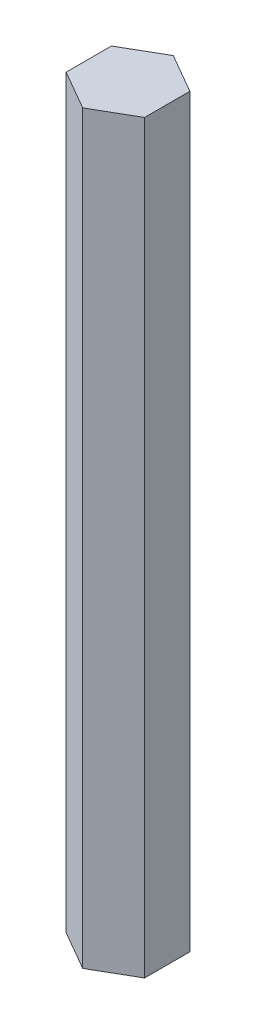
from build123d import *

# Parameters (mm, degrees)
BOSS_EXTRUDE1_DEPTH              = 120.65
F_10_32_TAPPED_HOLE1_D           = 4.0386
F_10_32_TAPPED_HOLE1_DEPTH       = 16.764
F_10_32_TAPPED_HOLE1_CBORE_D     = 4.826
F_10_32_TAPPED_HOLE1_CBORE_DEPTH = 12.7
F_10_32_TAPPED_HOLE1_TIP         = 1.213317848


with BuildPart() as part:
    # Sketch1 → Boss-Extrude1 (new body)
    with BuildSketch(Plane(origin=(0, 0, 0), x_dir=(1, 0, 0), z_dir=(0, 1, 0))):
        Polygon((0, 7.332348419), (-6.35, 3.666174209), (-6.35, -3.666174209), (0, -7.332348419), (6.35, -3.666174209), (6.35, 3.666174209), align=None)
    extrude(amount=BOSS_EXTRUDE1_DEPTH)

    # #10-32 Tapped Hole1
    with Locations(Plane(origin=(0, 0, 0), x_dir=(0, 0, -1), z_dir=(0, -1, 0))):
        with Locations((0, 0)):
            CounterBoreHole(F_10_32_TAPPED_HOLE1_D / 2, F_10_32_TAPPED_HOLE1_CBORE_D / 2, F_10_32_TAPPED_HOLE1_CBORE_DEPTH, depth=F_10_32_TAPPED_HOLE1_DEPTH)
            with Locations((0, 0, -(F_10_32_TAPPED_HOLE1_DEPTH + F_10_32_TAPPED_HOLE1_TIP / 2))):  # 118° drill point
                Cone(0, F_10_32_TAPPED_HOLE1_D / 2, F_10_32_TAPPED_HOLE1_TIP, mode=Mode.SUBTRACT)


solid = part.part
